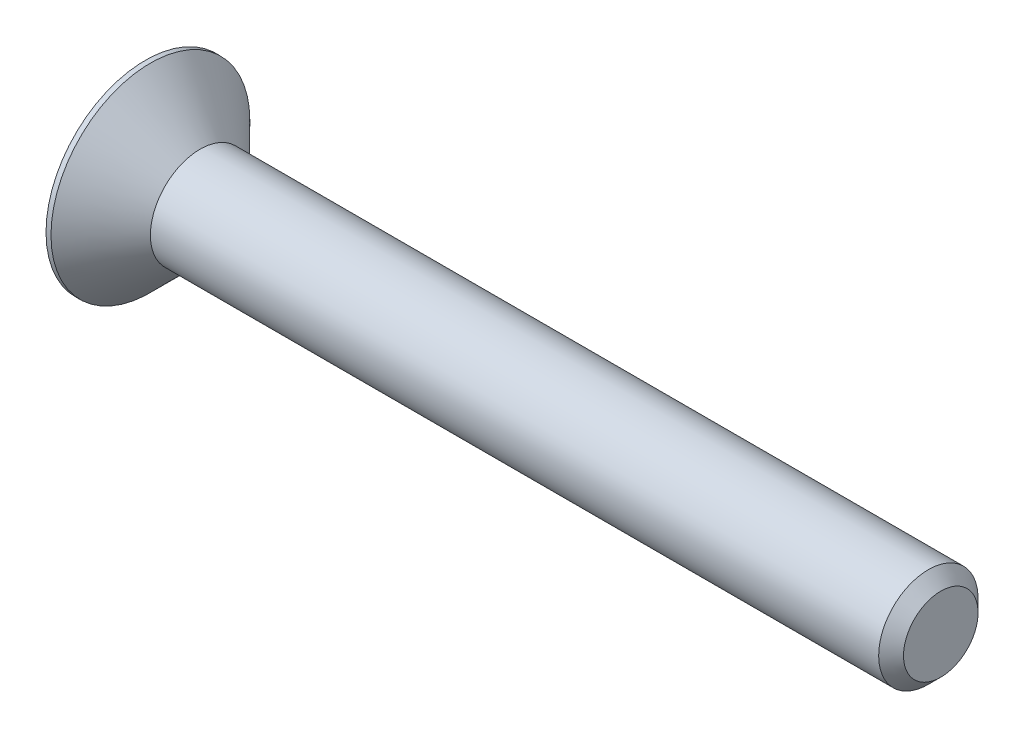
from build123d import *

# Parameters (mm, degrees)
CUT_EXTRUDE1_DEPTH = 0.8


with BuildPart() as part:
    # Sketch2 → Revolve1 (revolve)
    with BuildSketch(Plane.XY):
        Polygon((0, 0), (0, 2), (0.1, 2), (1.1, 1), (15.75, 1), (16, 0.75), (16, 0), align=None)
    revolve(axis=Axis((-2.281841559, 0, 0), (1, 0, 0)))

    # Sketch3 → Cut-Extrude1 (cut)
    with BuildSketch(Plane.ZY):
        Polygon((0.433012702, -0.75), (0.866025404, 0), (0.433012702, 0.75), (-0.433012702, 0.75), (-0.866025404, 0), (-0.433012702, -0.75), align=None)
    extrude(amount=-CUT_EXTRUDE1_DEPTH, mode=Mode.SUBTRACT)


solid = part.part
